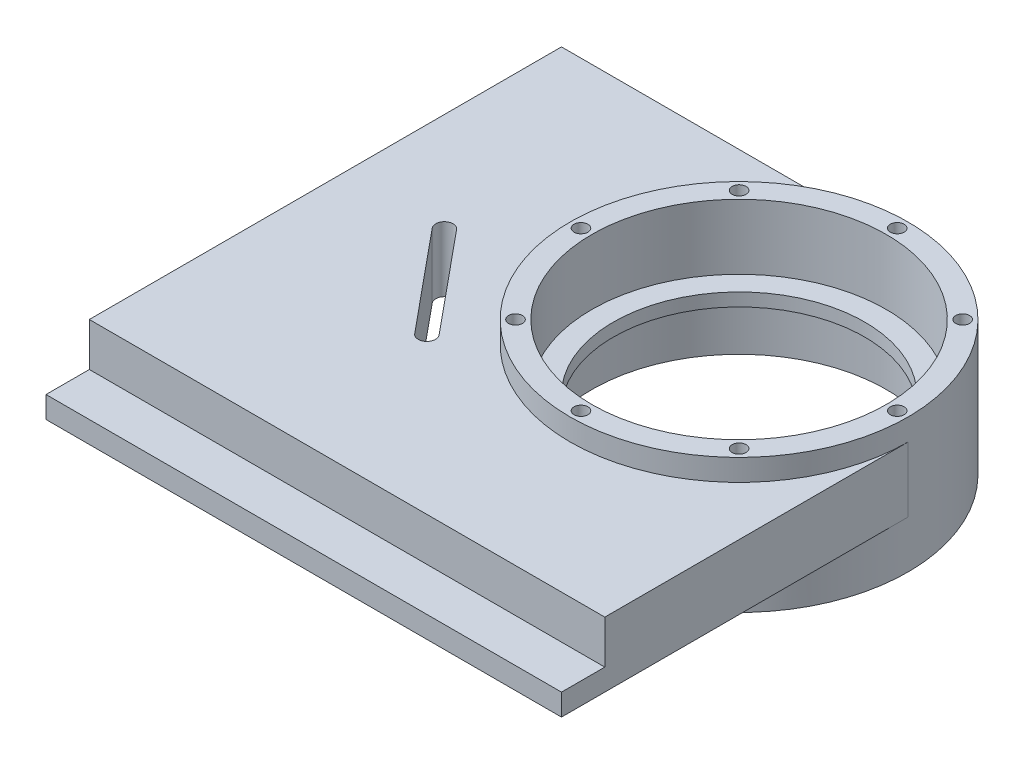
from build123d import *

# Parameters (mm, degrees)
SKETCH2_R                = 34
BOSS_EXTRUDE1_DEPTH      = 15
BOSS_EXTRUDE2_START      = -3
SKETCH2_3_R              = 39
SKETCH2_3_R_2            = 29
BOSS_EXTRUDE2_DEPTH      = 3
BOSS_EXTRUDE3_START      = -16
SKETCH2_4_R              = 34
BOSS_EXTRUDE3_DEPTH      = 16
BOSS_EXTRUDE4_DEPTH      = 10
BOSS_EXTRUDE4_DEPTH_BACK = 5
SKETCH3_W                = 119
SKETCH3_H                = 10
CUT_EXTRUDE1_DEPTH       = 10
SKETCH4_R                = 1.6
CUT_EXTRUDE2_DEPTH       = 7
CUT_EXTRUDE3_DEPTH       = 117.086174887


with BuildPart() as part:
    # Sketch2 → Boss-Extrude1 (new body)
    with BuildSketch(Plane(origin=(0, 0, 0), x_dir=(1, 0, 0), z_dir=(0, 1, 0))):
        with BuildLine():
            ThreePointArc((39, 0), (27.577164466, 27.577164466), (0, 39))
            ThreePointArc((0, 39), (-27.577164466, -27.577164466), (39, 0))
        make_face()
        Circle(SKETCH2_R, mode=Mode.SUBTRACT)
    extrude(amount=BOSS_EXTRUDE1_DEPTH)

    # Sketch2_3 → Boss-Extrude2 (add)
    with BuildSketch(Plane(origin=(0, 0, 0), x_dir=(1, 0, 0), z_dir=(0, 1, 0)).offset(BOSS_EXTRUDE2_START)):
        Circle(SKETCH2_3_R)
        Circle(SKETCH2_3_R_2, mode=Mode.SUBTRACT)
    extrude(amount=BOSS_EXTRUDE2_DEPTH)

    # Sketch2_4 → Boss-Extrude3 (add)
    with BuildSketch(Plane(origin=(0, 0, 0), x_dir=(1, 0, 0), z_dir=(0, 1, 0)).offset(BOSS_EXTRUDE3_START)):
        with BuildLine():
            ThreePointArc((39, 0), (27.577164466, 27.577164466), (0, 39))
            ThreePointArc((0, 39), (-27.577164466, -27.577164466), (39, 0))
        make_face()
        Circle(SKETCH2_4_R, mode=Mode.SUBTRACT)
    extrude(amount=BOSS_EXTRUDE3_DEPTH)

    # Sketch2_6 → Boss-Extrude4 (add, two sides: drawn at the far end of the back side and taken through both)
    with BuildSketch(Plane(origin=(0, 0, 0), x_dir=(1, 0, 0), z_dir=(0, 1, 0)).offset(-BOSS_EXTRUDE4_DEPTH_BACK)):
        with BuildLine():
            ThreePointArc((39, 0), (-27.577164466, -27.577164466), (0, 39))
            Line((0, 39), (-80, 39))
            Line((-80, 39), (-80, -80))
            Line((-80, -80), (0, -80))
            Line((0, -80), (39, -80))
            Line((39, -80), (39, 0))
        make_face()
    extrude(amount=BOSS_EXTRUDE4_DEPTH + BOSS_EXTRUDE4_DEPTH_BACK)

    # Sketch3 → Cut-Extrude1 (cut)
    with BuildSketch(Plane(origin=(0, 10, 0), x_dir=(1, 0, 0), z_dir=(0, 1, 0))):
        with Locations((-20.5, -75)):
            Rectangle(SKETCH3_W, SKETCH3_H)
    extrude(amount=-CUT_EXTRUDE1_DEPTH, mode=Mode.SUBTRACT)

    # Sketch4 → Cut-Extrude2 (cut)
    with BuildSketch(Plane(origin=(0, 15, 0), x_dir=(1, 0, 0), z_dir=(0, 1, 0))):
        with Locations((0, 36.5)):
            Circle(SKETCH4_R)
        with Locations((25.809397513, 25.809397513)):
            Circle(SKETCH4_R)
        with Locations((36.5, 0)):
            Circle(SKETCH4_R)
        with Locations((25.809397513, -25.809397513)):
            Circle(SKETCH4_R)
        with Locations((0, -36.5)):
            Circle(SKETCH4_R)
        with Locations((-25.809397513, -25.809397513)):
            Circle(SKETCH4_R)
        with Locations((-36.5, 0)):
            Circle(SKETCH4_R)
        with Locations((-25.809397513, 25.809397513)):
            Circle(SKETCH4_R)
    extrude(amount=-CUT_EXTRUDE2_DEPTH, mode=Mode.SUBTRACT)

    # Sketch5 → Cut-Extrude3 (cut, through all)
    with BuildSketch(Plane(origin=(0, 10, 0), x_dir=(1, 0, 0), z_dir=(0, 1, 0))):
        with BuildLine():
            Line((-55.608568551, -9.603906759), (-36.513231213, -32.741929405))
            ThreePointArc((-36.513231213, -32.741929405), (-36.782743567, -35.557486737), (-39.598300899, -35.287974383))
            Line((-39.598300899, -35.287974383), (-58.693638237, -12.149951738))
            ThreePointArc((-58.693638237, -12.149951738), (-58.424125883, -9.334394405), (-55.608568551, -9.603906759))
        make_face()
    extrude(amount=-CUT_EXTRUDE3_DEPTH, mode=Mode.SUBTRACT)


solid = part.part
